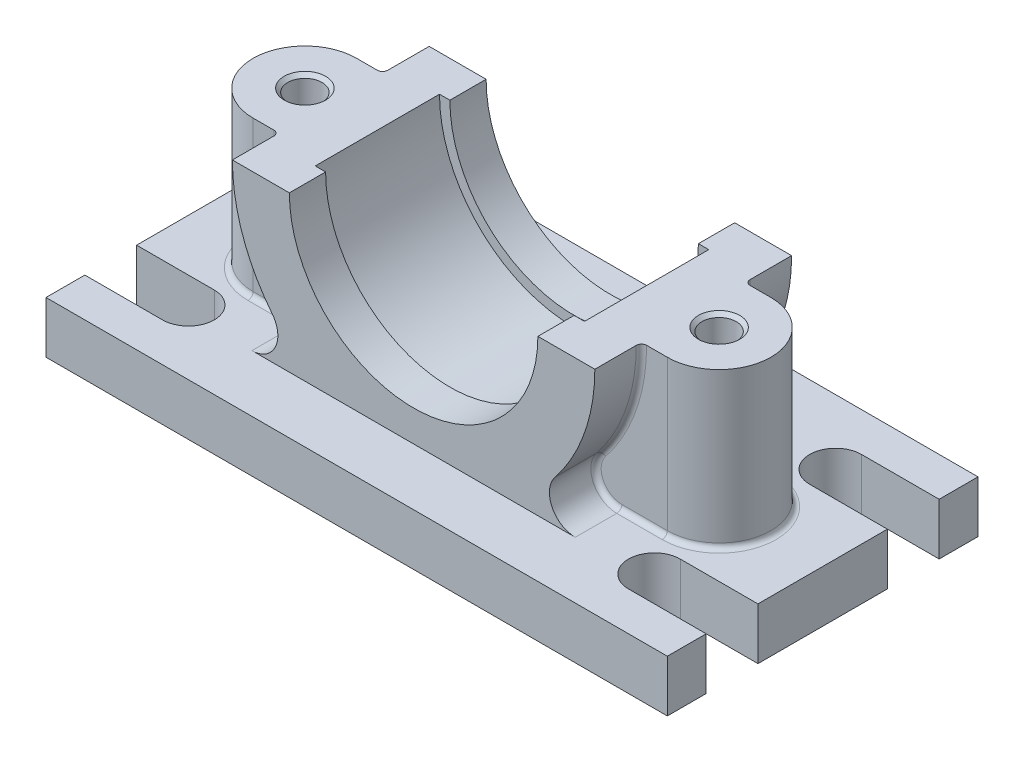
from build123d import *

# Parameters (mm, degrees)
EXTRUDE_2_DEPTH                 = 19
EXTRUDE_5_DEPTH                 = 40
CUT_EXTRUDE_1_REACH             = 68.791
SKETCH_1_4_R                    = 24
CUT_EXTRUDE_1_DIRECTION_2_REACH = 68.791
SKETCH_4_W                      = 120
SKETCH_4_H                      = 60
EXTRUDE_6_DEPTH                 = 10
FILLET_2_R                      = 5
CUT_EXTRUDE_2_DEPTH             = 79.102496759
MIRROR_2_COPY_1_DEPTH           = 79.102496759
MIRROR_2_COPY_2_DEPTH           = 79.102496759
CUT_EXTRUDE_3_DEPTH             = 12
CUT_EXTRUDE_4_DEPTH             = 12
FILLET_3_R                      = 4
FILLET_4_R                      = 2
SKETCH_7_R                      = 3.3095
CUT_EXTRUDE_5_DEPTH             = 25
FILLET_5_R                      = 1
CHAMFER_1_SIZE                  = 3.3
CHAMFER_2_SIZE                  = 0.6905


with BuildPart() as part:
    # Эскиз1 → Бобышка-Вытянуть2 (new, symmetric)
    with BuildSketch(Plane.XY):
        with BuildLine():
            ThreePointArc((24, 0), (0, -24), (-24, 0))
            Line((-24, 0), (-35, 0))
            ThreePointArc((-35, 0), (0, -35), (35, 0))
            Line((35, 0), (24, 0))
        make_face()
    extrude(amount=EXTRUDE_2_DEPTH, both=True)

    # Эскиз2 → Бобышка-Вытянуть5 (add)
    with BuildSketch(Plane(origin=(0, 0, 0), x_dir=(1, 0, 0), z_dir=(0, 1, 0))):
        with BuildLine():
            Line((-40, 10), (40, 10))
            ThreePointArc((40, 10), (50, 0), (40, -10))
            Line((40, -10), (-40, -10))
            ThreePointArc((-40, -10), (-50, 0), (-40, 10))
        make_face()
    extrude(amount=-EXTRUDE_5_DEPTH)

    # Эскиз1<4> → Вырез-Вытянуть1 (cut, up to next)
    with BuildSketch(Plane.XY, mode=Mode.PRIVATE) as cut_extrude_1_sk1:
        Circle(SKETCH_1_4_R)
    cut_extrude_1_tool1 = extrude(cut_extrude_1_sk1.sketch, amount=-CUT_EXTRUDE_1_REACH, mode=Mode.PRIVATE) & part.part
    add(cut_extrude_1_tool1.solids().sort_by_distance((0, 0, 0))[0], mode=Mode.SUBTRACT)

    # Эскиз1<4> → Вырез-Вытянуть1 direction 2 (cut, up to next)
    with BuildSketch(Plane.XY, mode=Mode.PRIVATE) as cut_extrude_1_direction_2_sk1:
        Circle(SKETCH_1_4_R)
    cut_extrude_1_direction_2_tool1 = extrude(cut_extrude_1_direction_2_sk1.sketch, amount=CUT_EXTRUDE_1_DIRECTION_2_REACH, mode=Mode.PRIVATE) & part.part
    add(cut_extrude_1_direction_2_tool1.solids().sort_by_distance((0, 0, 0))[0], mode=Mode.SUBTRACT)

    # Эскиз4 → Бобышка-Вытянуть6 (add)
    with BuildSketch(Plane.XZ.offset(40)):
        Rectangle(SKETCH_4_W, SKETCH_4_H)
    extrude(amount=-EXTRUDE_6_DEPTH)

    # Скругление2
    fillet_2_edges = [part.edges().sort_by_distance(p)[0] for p in [
        (18.027756377, -30, 14.5),
        (18.027756377, -30, -14.5),
        (-18.027756377, -30, -14.5),
        (-18.027756377, -30, 14.5),
    ]]
    fillet(fillet_2_edges, radius=FILLET_2_R)

    # Эскиз5 → Вырез-Вытянуть2 (cut, through all)
    with BuildSketch(Plane.XZ.offset(40)):
        with BuildLine():
            Line((75, -22.5), (45, -22.5))
            ThreePointArc((45, -22.5), (40, -17.5), (45, -12.5))
            Line((45, -12.5), (75, -12.5))
            ThreePointArc((75, -12.5), (80, -17.5), (75, -22.5))
        make_face()
    cut_extrude_2 = extrude(amount=-CUT_EXTRUDE_2_DEPTH, mode=Mode.SUBTRACT)

    # Зеркальное отражение1: Вырез-Вытянуть2 across plane
    add(cut_extrude_2.mirror(Plane.XY), mode=Mode.SUBTRACT)

    # Зеркальное отражение2 copy 1 sketch → Зеркальное отражение2 copy 1 (cut, through all)
    with BuildSketch(Plane(origin=(0, -40, 0), x_dir=(-1, 0, 0), z_dir=(0, -1, 0))):
        with BuildLine():
            Line((75, -22.5), (45, -22.5))
            ThreePointArc((45, -22.5), (40, -17.5), (45, -12.5))
            Line((45, -12.5), (75, -12.5))
            ThreePointArc((75, -12.5), (80, -17.5), (75, -22.5))
        make_face()
    extrude(amount=-MIRROR_2_COPY_1_DEPTH, mode=Mode.SUBTRACT)

    # Зеркальное отражение2 copy 2 sketch → Зеркальное отражение2 copy 2 (cut, through all)
    with BuildSketch(Plane(origin=(0, -40, 0), x_dir=(-1, 0, 0), z_dir=(0, -1, 0))):
        with BuildLine():
            Line((75, 22.5), (45, 22.5))
            ThreePointArc((45, 22.5), (40, 17.5), (45, 12.5))
            Line((45, 12.5), (75, 12.5))
            ThreePointArc((75, 12.5), (80, 17.5), (75, 22.5))
        make_face()
    extrude(amount=-MIRROR_2_COPY_2_DEPTH, mode=Mode.SUBTRACT)

    # Эскиз1<5> → Вырез-Вытянуть3 (cut, symmetric)
    with BuildSketch(Plane.XY):
        with BuildLine():
            Line((26, 0), (24, 0))
            ThreePointArc((24, 0), (0, -24), (-24, 0))
            Line((-24, 0), (-26, 0))
            ThreePointArc((-26, 0), (0, -26), (26, 0))
        make_face()
    extrude(amount=CUT_EXTRUDE_3_DEPTH, both=True, mode=Mode.SUBTRACT)

    # Эскиз6 → Вырез-Вытянуть4 (cut, symmetric)
    with BuildSketch(Plane.XY):
        with BuildLine():
            Line((0, -34), (0, -40))
            Line((0, -40), (25, -40))
            Line((25, -40), (25, -23.043437244))
            ThreePointArc((25, -23.043437244), (13.647767834, -31.140623519), (0, -34))
        make_face()
    cut_extrude_4 = extrude(amount=CUT_EXTRUDE_4_DEPTH, both=True, mode=Mode.SUBTRACT)

    # Зеркальное отражение3: Вырез-Вытянуть4 across plane
    add(cut_extrude_4.mirror(Plane(origin=(0, -34, -12), x_dir=(0, 0, 1), z_dir=(-1, 0, 0))), mode=Mode.SUBTRACT)

    # Скругление3
    fillet_3_edges = [part.edges().sort_by_distance(p)[0] for p in [
        (25, -23.043437244, 0),
        (-25, -23.043437244, 0),
    ]]
    fillet(fillet_3_edges, radius=FILLET_3_R)

    # Скругление4
    fillet_4_edges = [part.edges().sort_by_distance(p)[0] for p in [
        (-25, -35.835087622, 12),
        (-22.891810606, -28.145823867, 12),
        (25, -35.835087622, 12),
        (22.891810606, -28.145823867, 12),
        (-25, -35.835087622, -12),
        (-22.891810606, -28.145823867, -12),
        (25, -35.835087622, -12),
        (22.891810606, -28.145823867, -12),
        (0, -34, 12),
        (0, -34, -12),
        (0, -40, 12),
        (-25, -40, 0),
        (25, -40, 0),
        (0, -40, -12),
    ]]
    fillet(fillet_4_edges, radius=FILLET_4_R)

    # Эскиз7 → Вырез-Вытянуть5 (cut)
    with BuildSketch(Plane(origin=(0, 0, 0), x_dir=(1, 0, 0), z_dir=(0, 1, 0))):
        with Locations((-40, 0)):
            Circle(SKETCH_7_R)
        with Locations((40, 0)):
            Circle(SKETCH_7_R)
    extrude(amount=-CUT_EXTRUDE_5_DEPTH, mode=Mode.SUBTRACT)

    # Скругление5
    fillet_5_edges = [part.edges().sort_by_distance(p)[0] for p in [
        (33.024727997, -11.591692747, -10),
        (26.718050898, -27.165063509, -10),
        (35.612494996, -30, -10),
        (50, -30, 0),
        (35.612494996, -30, 10),
        (26.718050898, -27.165063509, 10),
        (-33.024727997, -11.591692747, 10),
        (-26.718050898, -27.165063509, 10),
        (-33.024727997, -11.591692747, -10),
        (-26.718050898, -27.165063509, -10),
        (-35.612494996, -30, -10),
        (-50, -30, 0),
        (33.024727997, -11.591692747, 10),
        (-35.612494996, -30, 10),
    ]]
    fillet(fillet_5_edges, radius=FILLET_5_R)

    # Фаска1
    chamfer_1_edges = [part.edges().sort_by_distance(p)[0] for p in [
        (36.6905, -25, 0),
        (-43.3095, -25, 0),
    ]]
    chamfer(chamfer_1_edges, length=CHAMFER_1_SIZE)

    # Фаска2
    chamfer_2_edges = [part.edges().sort_by_distance(p)[0] for p in [
        (36.6905, 0, 0),
        (-43.3095, 0, 0),
    ]]
    chamfer(chamfer_2_edges, length=CHAMFER_2_SIZE)


solid = part.part
